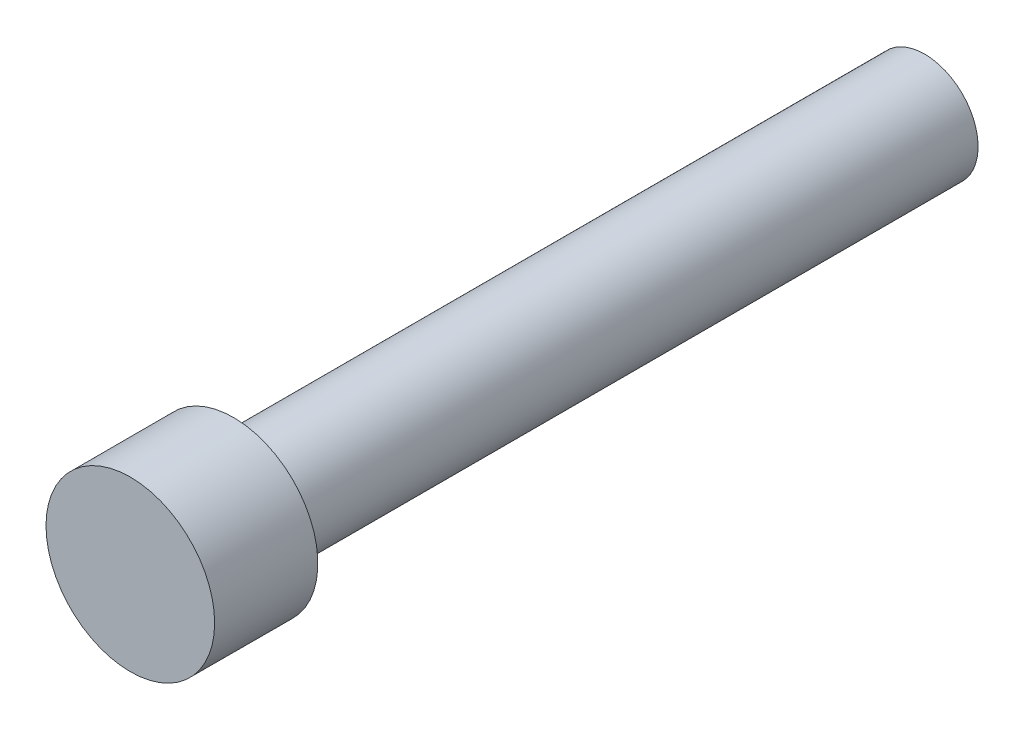
from build123d import *

# Parameters (mm, degrees)
SKETCH1_R         = 2.3241
EXTRUDE1_DEPTH    = 21.8948
SKETCH3_OUTSIDE_W = 11.22
SKETCH3_OUTSIDE_H = 11.22
SKETCH3_OUTSIDE_R = 1.4732
EXTRUDE2_DEPTH    = 19.05


with BuildPart() as part:
    # Sketch1 → Extrude1 (new body)
    with BuildSketch(Plane.XY):
        Circle(SKETCH1_R)
    extrude(amount=EXTRUDE1_DEPTH)

    # Sketch3 outside → Extrude2 (cut)
    with BuildSketch(Plane(origin=(0, 0, 0), x_dir=(-1, 0, 0), z_dir=(0, 0, -1))):
        Rectangle(SKETCH3_OUTSIDE_W, SKETCH3_OUTSIDE_H)
        Circle(SKETCH3_OUTSIDE_R, mode=Mode.SUBTRACT)
    extrude(amount=-EXTRUDE2_DEPTH, mode=Mode.SUBTRACT)


solid = part.part
